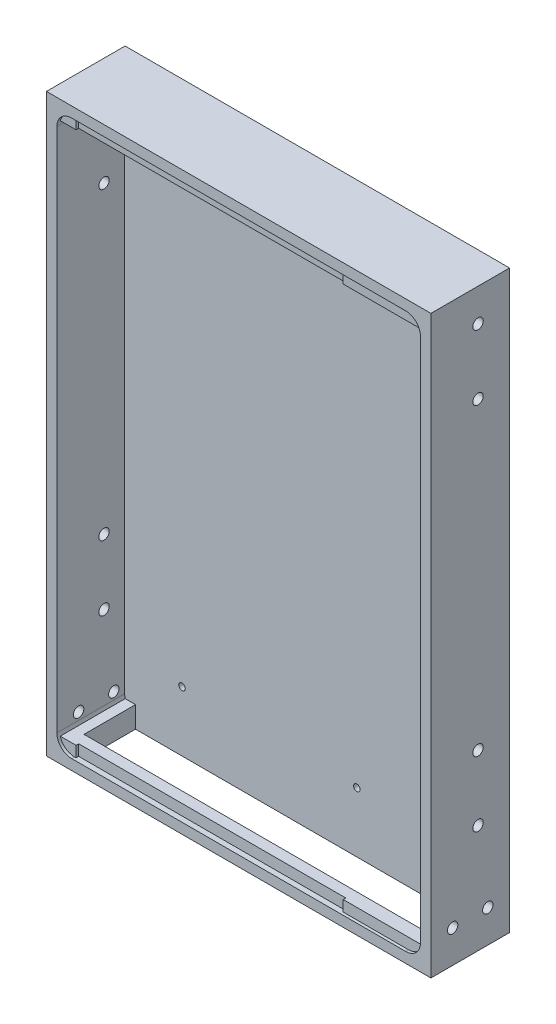
from build123d import *

# Parameters (mm, degrees)
SKETCH1_W           = 177
SKETCH1_H           = 265
SKETCH1_R           = 1.5
BOSS_EXTRUDE1_DEPTH = 5
SKETCH2_W           = 177
SKETCH2_H           = 265
SKETCH2_W_2         = 167.4
SKETCH2_H_2         = 255.4
BOSS_EXTRUDE2_DEPTH = 31.2
FILLET1_R           = 6.82
BOSS_EXTRUDE3_DEPTH = 29.9
SKETCH5_W           = 123
SKETCH5_H           = 5
CUT_EXTRUDE1_DEPTH  = 1.2
SKETCH9_W           = 157.4
SKETCH9_H           = 23.7
CUT_EXTRUDE3_DEPTH  = 10.8
SKETCH10_R          = 2.4
CUT_EXTRUDE4_DEPTH  = 178
SKETCH16_R          = 2.4
CUT_EXTRUDE7_DEPTH  = 177


with BuildPart() as part:
    # Sketch1 → Boss-Extrude1 (new body)
    with BuildSketch(Plane.XY):
        Rectangle(SKETCH1_W, SKETCH1_H)
        with Locations((-57.3, -104.9)):
            Circle(SKETCH1_R, mode=Mode.SUBTRACT)
        with Locations((23.21, -104.9)):
            Circle(SKETCH1_R, mode=Mode.SUBTRACT)
        with Locations((23.21, 104.9)):
            Circle(SKETCH1_R, mode=Mode.SUBTRACT)
        with Locations((-57.3, 104.9)):
            Circle(SKETCH1_R, mode=Mode.SUBTRACT)
    extrude(amount=BOSS_EXTRUDE1_DEPTH)

    # Sketch2 → Boss-Extrude2 (add)
    with BuildSketch(Plane.XY.offset(5)):
        Rectangle(SKETCH2_W, SKETCH2_H)
        Rectangle(SKETCH2_W_2, SKETCH2_H_2, mode=Mode.SUBTRACT)
    extrude(amount=BOSS_EXTRUDE2_DEPTH)

    # Fillet1
    fillet1_edges = [part.edges().sort_by_distance(p)[0] for p in [
        (83.7, -127.7, 20.6),
        (83.7, 127.7, 20.6),
        (-83.7, 127.7, 20.6),
        (-83.7, -127.7, 20.6),
    ]]
    fillet(fillet1_edges, radius=FILLET1_R)

    # Sketch4 → Boss-Extrude3 (add)
    with BuildSketch(Plane.XY.offset(5)):
        with BuildLine():
            Line((83.45267069, -122.7), (-83.45267069, -122.7))
            ThreePointArc((-83.45267069, -122.7), (-81.009164564, -126.307927781), (-76.88, -127.7))
            Line((-76.88, -127.7), (76.88, -127.7))
            ThreePointArc((76.88, -127.7), (81.009164564, -126.307927781), (83.45267069, -122.7))
        make_face()
        with BuildLine():
            ThreePointArc((-76.88, 127.7), (-81.009164564, 126.307927781), (-83.45267069, 122.7))
            Line((-83.45267069, 122.7), (83.45267069, 122.7))
            ThreePointArc((83.45267069, 122.7), (81.009164564, 126.307927781), (76.88, 127.7))
            Line((76.88, 127.7), (-76.88, 127.7))
        make_face()
    extrude(amount=BOSS_EXTRUDE3_DEPTH)

    # Sketch5 → Cut-Extrude1 (cut)
    with BuildSketch(Plane.XY.offset(34.9)):
        with Locations((-14.66, -125.2)):
            Rectangle(SKETCH5_W, SKETCH5_H)
        with Locations((-14.66, 125.2)):
            Rectangle(SKETCH5_W, SKETCH5_H)
    extrude(amount=-CUT_EXTRUDE1_DEPTH, mode=Mode.SUBTRACT)

    # Sketch9 → Cut-Extrude3 (cut, through all)
    with BuildSketch(Plane(origin=(0, -122.7, 0), x_dir=(1, 0, 0), z_dir=(0, 1, 0))):
        with Locations((0, -16.85)):
            Rectangle(SKETCH9_W, SKETCH9_H)
    extrude(amount=-CUT_EXTRUDE3_DEPTH, mode=Mode.SUBTRACT)

    # Sketch10 → Cut-Extrude4 (cut, through all)
    with BuildSketch(Plane(origin=(88.5, 0, 0), x_dir=(0, 0, -1), z_dir=(1, 0, 0))):
        with Locations((-10, -117.5)):
            Circle(SKETCH10_R)
        with Locations((-26.2, -117.5)):
            Circle(SKETCH10_R)
    extrude(amount=-CUT_EXTRUDE4_DEPTH, mode=Mode.SUBTRACT)

    # Sketch16 → Cut-Extrude7 (cut)
    with BuildSketch(Plane(origin=(88.5, 0, 0), x_dir=(0, 0, -1), z_dir=(1, 0, 0))):
        with Locations((-14.5, 117.5)):
            Circle(SKETCH16_R)
        with Locations((-14.5, 87.5)):
            Circle(SKETCH16_R)
        with Locations((-14.5, -52.5)):
            Circle(SKETCH16_R)
        with Locations((-14.5, -82.5)):
            Circle(SKETCH16_R)
    extrude(amount=-CUT_EXTRUDE7_DEPTH, mode=Mode.SUBTRACT)


solid = part.part
